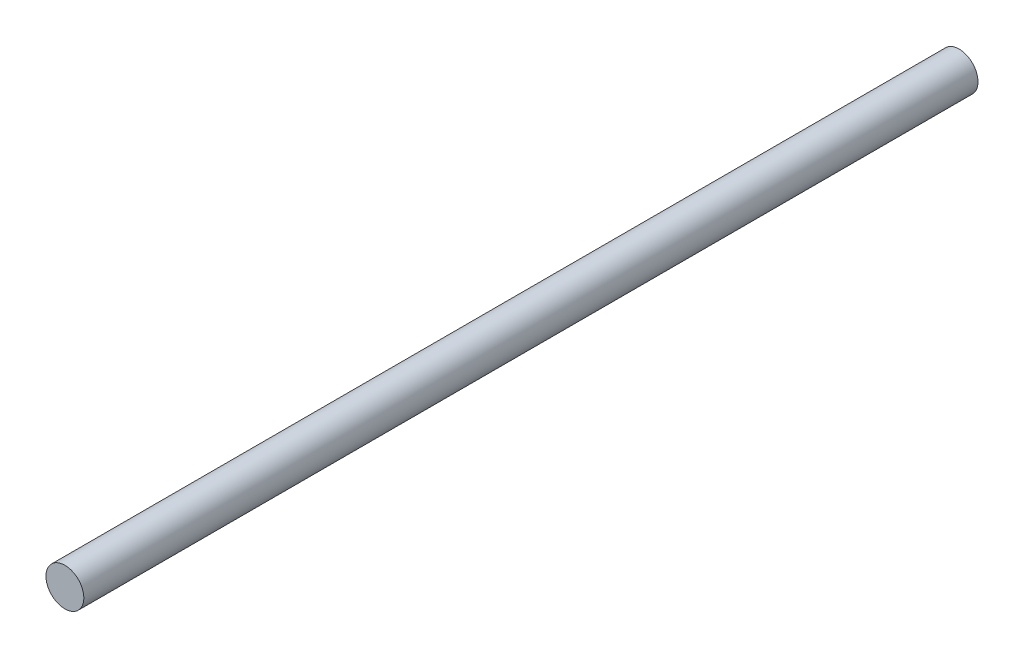
from build123d import *

# Parameters (mm, degrees)
CROQUIS1_R = 6.35


with BuildPart() as part:
    # Barrer1: sweep along a path in Croquis2
    with BuildLine(Plane(origin=(0, 0, 0), x_dir=(0, 0, -1), z_dir=(1, 0, 0))) as barrer1_path:
        Line((0, 0), (300, 0))
    # Croquis1 → Barrer1 (sweep)
    with BuildSketch(Plane.XY):
        Circle(CROQUIS1_R)
    sweep(path=barrer1_path.line)


solid = part.part
